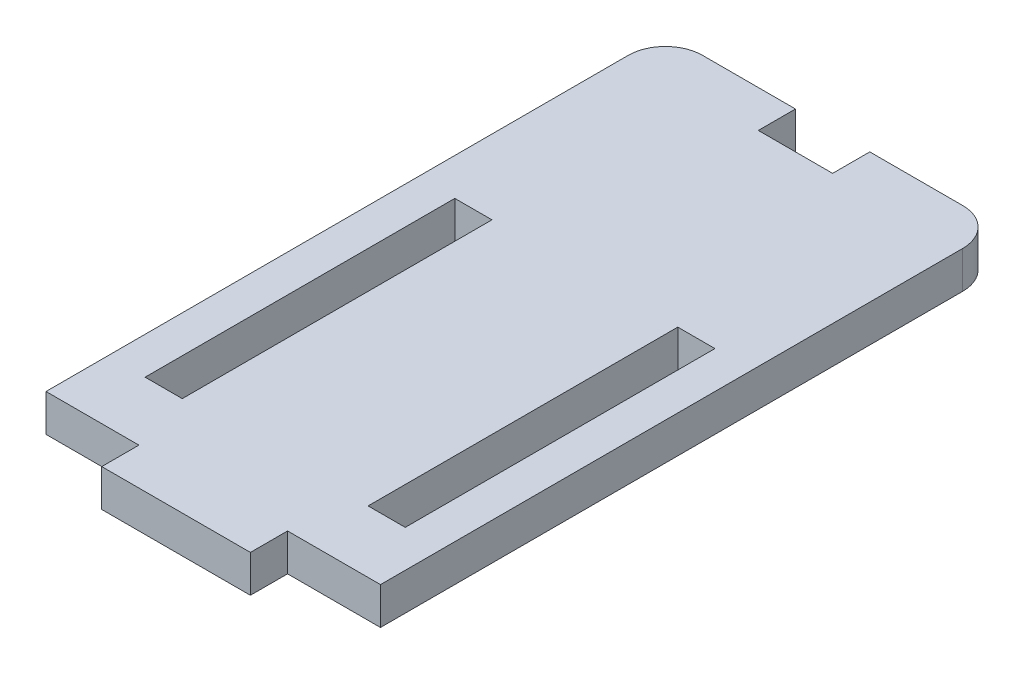
from build123d import *

# Parameters (mm, degrees)
SKETCH1_W               = 27
SKETCH1_H               = 50
BOSS_EXTRUDE1_DEPTH     = 1.5
SKETCH2_W               = 12
SKETCH2_H               = 3
BOSS_EXTRUDE2_DEPTH     = 1.5
SKETCH4_W               = 3
SKETCH4_H               = 25
CUT_EXTRUDE1_DEPTH      = 2.5
CUT_EXTRUDE1_DEPTH_BACK = 2.5
FILLET1_R               = 3
SKETCH5_W               = 6
SKETCH5_H               = 3
CUT_EXTRUDE2_DEPTH      = 2.5
CUT_EXTRUDE2_DEPTH_BACK = 2.5


with BuildPart() as part:
    # Sketch1 → Boss-Extrude1 (new body, symmetric)
    with BuildSketch(Plane(origin=(0, 0, 0), x_dir=(1, 0, 0), z_dir=(0, 1, 0))):
        Rectangle(SKETCH1_W, SKETCH1_H)
    extrude(amount=BOSS_EXTRUDE1_DEPTH, both=True)

    # Sketch2 → Boss-Extrude2 (add, symmetric)
    with BuildSketch(Plane(origin=(0, 0, 0), x_dir=(1, 0, 0), z_dir=(0, 1, 0))):
        with Locations((0, -26.5)):
            Rectangle(SKETCH2_W, SKETCH2_H)
    extrude(amount=BOSS_EXTRUDE2_DEPTH, both=True)

    # Sketch4 → Cut-Extrude1 (cut, two sides)
    with BuildSketch(Plane(origin=(0, 0, 0), x_dir=(1, 0, 0), z_dir=(0, 1, 0))) as cut_extrude1_sk:
        with Locations((-9, -7.5)):
            Rectangle(SKETCH4_W, SKETCH4_H)
        with Locations((9, -7.5)):
            Rectangle(SKETCH4_W, SKETCH4_H)
    extrude(amount=CUT_EXTRUDE1_DEPTH, mode=Mode.SUBTRACT)
    extrude(cut_extrude1_sk.sketch, amount=-CUT_EXTRUDE1_DEPTH_BACK, mode=Mode.SUBTRACT)

    # Fillet1
    fillet1_edges = [part.edges().sort_by_distance(p)[0] for p in [
        (-13.5, 0, -25),
        (13.5, 0, -25),
    ]]
    fillet(fillet1_edges, radius=FILLET1_R)

    # Sketch5 → Cut-Extrude2 (cut, two sides)
    with BuildSketch(Plane(origin=(0, 0, 0), x_dir=(1, 0, 0), z_dir=(0, 1, 0))) as cut_extrude2_sk:
        with Locations((0, 23.5)):
            Rectangle(SKETCH5_W, SKETCH5_H)
    extrude(amount=CUT_EXTRUDE2_DEPTH, mode=Mode.SUBTRACT)
    extrude(cut_extrude2_sk.sketch, amount=-CUT_EXTRUDE2_DEPTH_BACK, mode=Mode.SUBTRACT)


solid = part.part
